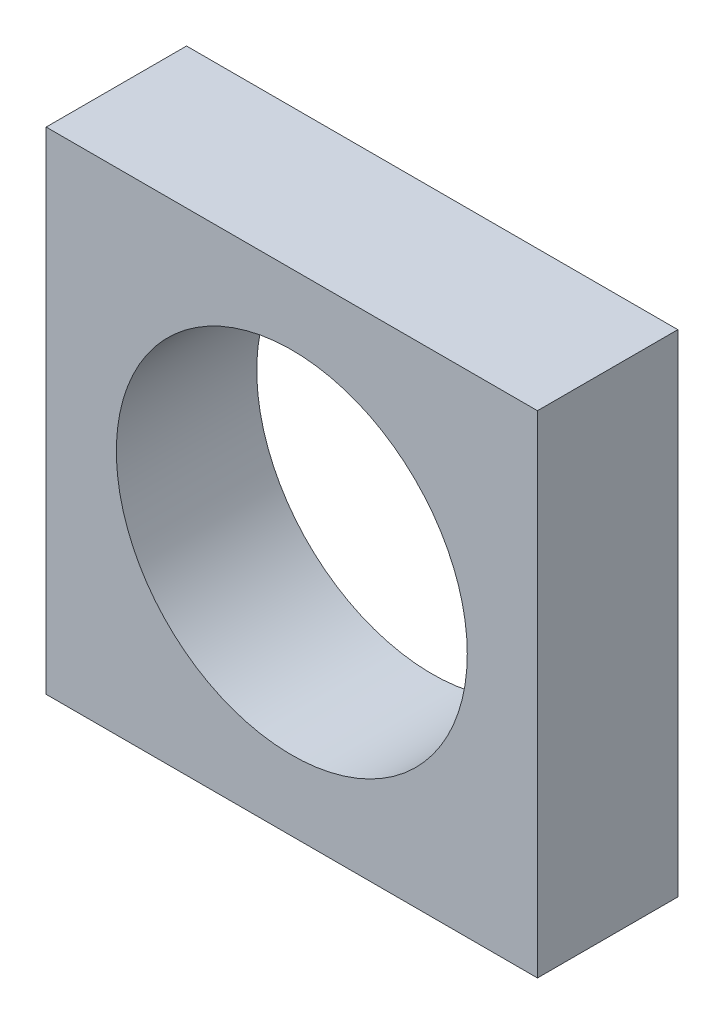
from build123d import *

# Parameters (mm, degrees)
SKETCH1_W           = 7
SKETCH1_H           = 7
SKETCH1_R           = 2.5
BOSS_EXTRUDE1_DEPTH = 1


with BuildPart() as part:
    # Sketch1 → Boss-Extrude1 (new body, symmetric)
    with BuildSketch(Plane.XY):
        Rectangle(SKETCH1_W, SKETCH1_H)
        Circle(SKETCH1_R, mode=Mode.SUBTRACT)
    extrude(amount=BOSS_EXTRUDE1_DEPTH, both=True)


solid = part.part
